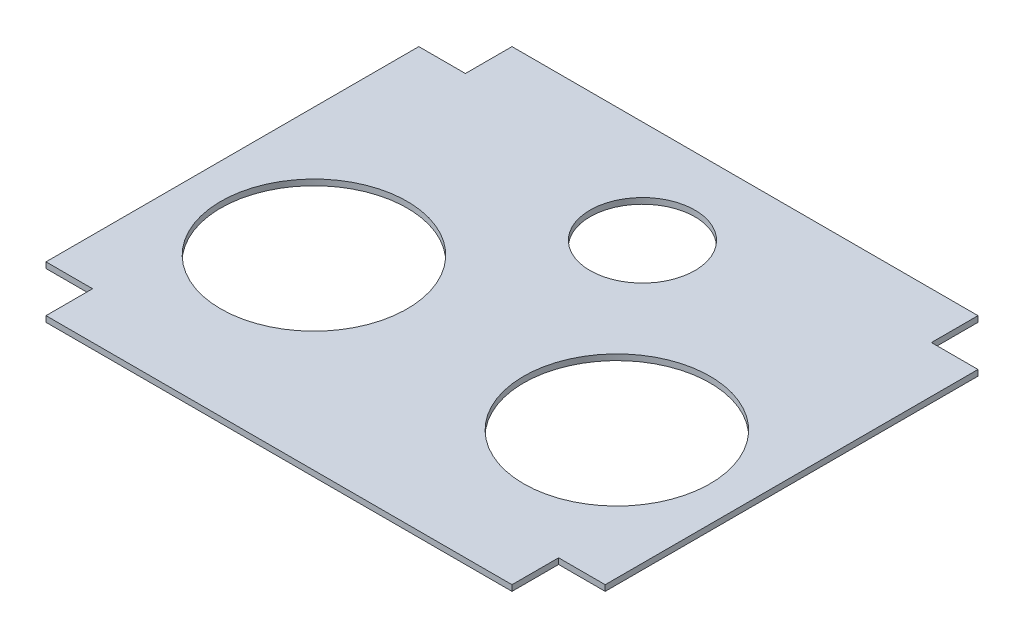
from build123d import *

# Parameters (mm, degrees)
SKETCH1_R           = 101.6
SKETCH1_R_2         = 57.15
BOSS_EXTRUDE1_DEPTH = 6.35


with BuildPart() as part:
    # Sketch1 → Boss-Extrude1 (new body)
    with BuildSketch(Plane(origin=(0, 0, 0), x_dir=(1, 0, 0), z_dir=(0, 1, 0))):
        Polygon((0, 0), (0, -50.8), (-508, -50.8), (-508, 0), (-558.8, 0), (-558.8, 406.4), (-508, 406.4), (-508, 457.2), (0, 457.2), (0, 406.4), (50.8, 406.4), (50.8, 0), align=None)
        with Locations((-419.1, 152.4)):
            Circle(SKETCH1_R, mode=Mode.SUBTRACT)
        with Locations((-88.9, 152.4)):
            Circle(SKETCH1_R, mode=Mode.SUBTRACT)
        with Locations((-254, 345.42328875)):
            Circle(SKETCH1_R_2, mode=Mode.SUBTRACT)
    extrude(amount=BOSS_EXTRUDE1_DEPTH)


solid = part.part
